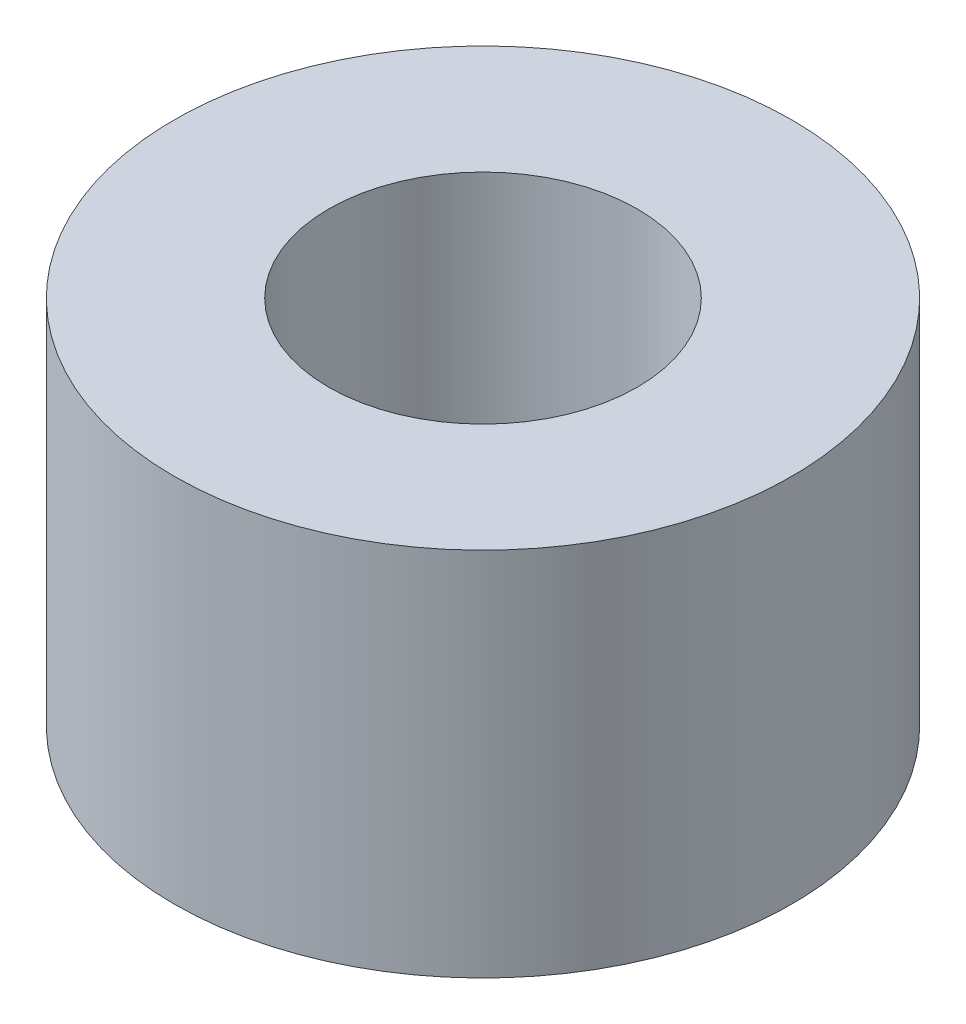
from build123d import *

# Parameters (mm, degrees)
SKETCH2_R           = 2.5
SKETCH2_R_2         = 1.25
BOSS_EXTRUDE1_DEPTH = 3


with BuildPart() as part:
    # Sketch2 → Boss-Extrude1 (new body)
    with BuildSketch(Plane(origin=(0, 0, 0), x_dir=(1, 0, 0), z_dir=(0, 1, 0))):
        Circle(SKETCH2_R)
        Circle(SKETCH2_R_2, mode=Mode.SUBTRACT)
    extrude(amount=BOSS_EXTRUDE1_DEPTH)


solid = part.part
